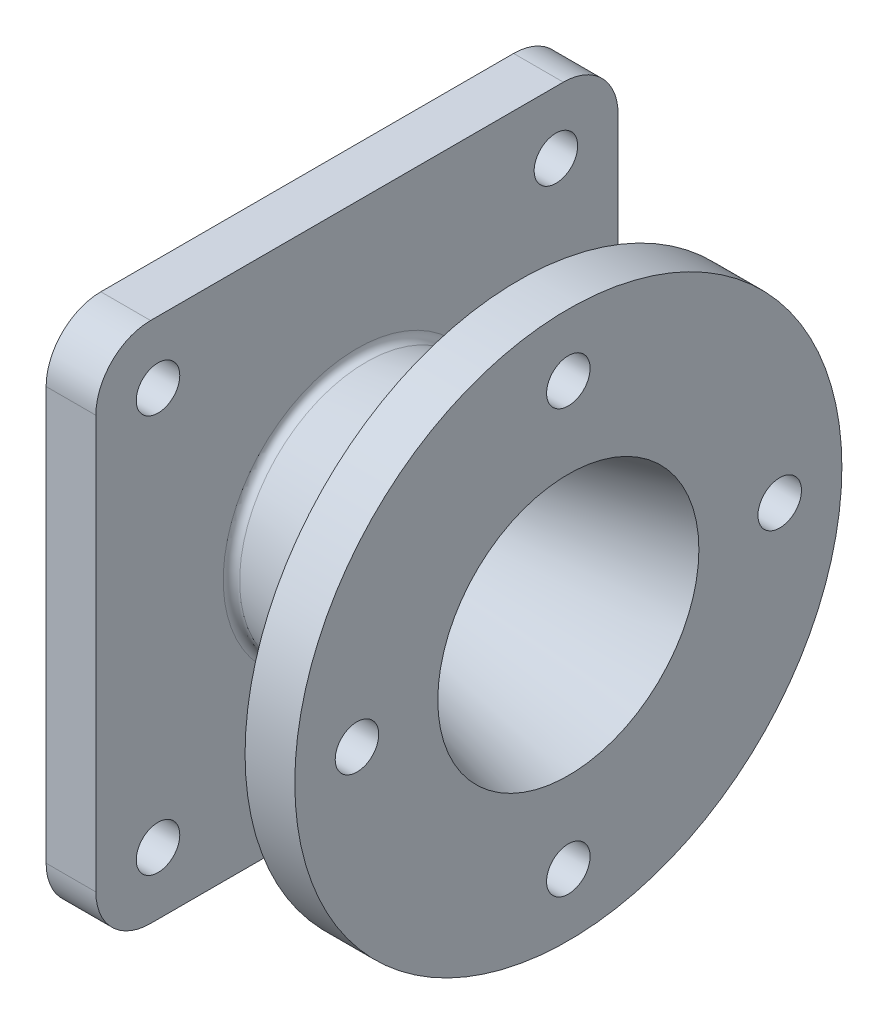
from build123d import *

# Parameters (mm, degrees)
SKETCH_2_R               = 8.75
CUT_EXTRUDE_1_DEPTH      = 20
PATTERN_CIRCULAR_1_COUNT = 4
SKETCH_3_W               = 210
SKETCH_3_H               = 210
SKETCH_3_R               = 35
EXTRUDE_1_DEPTH          = 20
SKETCH_4_R               = 8.75
CUT_EXTRUDE_2_DEPTH      = 20
FILLET_1_R               = 22
PATTERN_CIRCULAR_5_COUNT = 4
CHAMFER_1_SIZE           = 3.2875
FILLET_2_R               = 3


with BuildPart() as part:
    # Эскиз1 → Повернуть1 (revolve)
    with BuildSketch(Plane.XY):
        Polygon((0, 52.5), (0, 110), (-20, 110), (-20, 65), (-85, 50), (-85, 105), (-105, 105), (-105, 62.5), (-130, 62.5), (-130, 28.7125), (-113, 28.7125), (-113, 35), (-105, 35), (-105, 25), align=None)
    revolve(axis=Axis((0, 0, 0), (-1, 0, 0)))

    # Эскиз2 → Вырез-Вытянуть1 (cut)
    with BuildSketch(Plane(origin=(0, 0, 0), x_dir=(0, 0, -1), z_dir=(1, 0, 0))):
        with Locations((0, 85)):
            Circle(SKETCH_2_R)
    cut_extrude_1 = extrude(amount=-CUT_EXTRUDE_1_DEPTH, mode=Mode.SUBTRACT)

    # Круговой массив1: Вырез-Вытянуть1 ×4 about axis
    pattern_circular_1_axis = Axis((0, 0, 0), (1, 0, 0))
    for i in range(1, PATTERN_CIRCULAR_1_COUNT):
        add(cut_extrude_1.rotate(pattern_circular_1_axis, i * 360 / PATTERN_CIRCULAR_1_COUNT), mode=Mode.SUBTRACT)

    # Эскиз3 → Бобышка-Вытянуть1 (add)
    with BuildSketch(Plane.ZY.offset(105)):
        Rectangle(SKETCH_3_W, SKETCH_3_H)
        Circle(SKETCH_3_R, mode=Mode.SUBTRACT)
    extrude(amount=-EXTRUDE_1_DEPTH)

    # Эскиз4 → Вырез-Вытянуть2 (cut)
    with BuildSketch(Plane.ZY.offset(105)):
        with Locations((80, 80)):
            Circle(SKETCH_4_R)
    cut_extrude_2 = extrude(amount=-CUT_EXTRUDE_2_DEPTH, mode=Mode.SUBTRACT)

    # Скругление1
    fillet_1_edges = [part.edges().sort_by_distance(p)[0] for p in [
        (-95, 105, 105),
        (-95, -105, 105),
        (-95, -105, -105),
        (-95, 105, -105),
    ]]
    fillet(fillet_1_edges, radius=FILLET_1_R)

    # Круговой массив5: Вырез-Вытянуть2 ×4 about axis
    pattern_circular_5_axis = Axis((0, 0, 0), (1, 0, 0))
    for i in range(1, PATTERN_CIRCULAR_5_COUNT):
        add(cut_extrude_2.rotate(pattern_circular_5_axis, i * 360 / PATTERN_CIRCULAR_5_COUNT), mode=Mode.SUBTRACT)

    # Фаска1
    chamfer_1_edges = [part.edges().sort_by_distance(p)[0] for p in [
        (-130, -28.7125, 0),
    ]]
    chamfer(chamfer_1_edges, length=CHAMFER_1_SIZE)

    # Скругление2
    fillet_2_edges = [part.edges().sort_by_distance(p)[0] for p in [
        (-20, -65, 0),
        (-85, -50, 0),
    ]]
    fillet(fillet_2_edges, radius=FILLET_2_R)


solid = part.part
